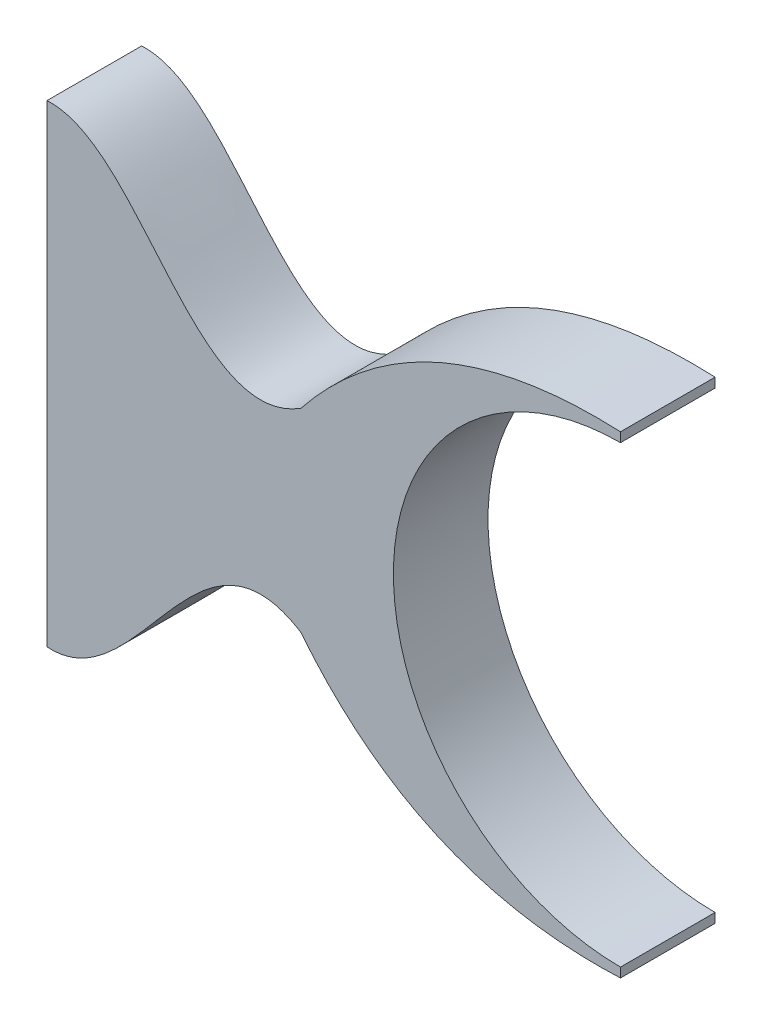
from build123d import *

# Parameters (mm, degrees)
BOSS_EXTRUDE1_DEPTH = 1


with BuildPart() as part:
    # Sketch1 → Boss-Extrude1 (new body)
    with BuildSketch(Plane.XY):
        with BuildLine():
            Line((-6.062552239, 2.5), (-6.062552239, -2.5))
            add(Edge.make_bspline(
                [(-3.378314474, -1.025559537), (-4.49216768, -0.325238314), (-5.082460235, -2.568455815), (-6.062552239, -2.5)],
                knots=[0, 0, 0, 0, 1, 1, 1, 1], degree=3))
            add(Edge.make_bspline(
                [(0, -2.5), (-2.128381344, -2.596064875), (-3.378314474, -1.025559537)],
                knots=[0, 0, 0, 1, 1, 1], degree=2))
            Line((0, -2.5), (0, -2.4))
            ThreePointArc((0, -2.4), (-2.4, 0), (0, 2.4))
            Line((0, 2.4), (0, 2.5))
            add(Edge.make_bspline(
                [(0, 2.5), (-2.128381344, 2.596064875), (-3.378314474, 1.025559537)],
                knots=[0, 0, 0, 1, 1, 1], degree=2))
            add(Edge.make_bspline(
                [(-3.378314474, 1.025559537), (-4.49216768, 0.325238314), (-5.082460235, 2.568455815), (-6.062552239, 2.5)],
                knots=[0, 0, 0, 0, 1, 1, 1, 1], degree=3))
        make_face()
    extrude(amount=BOSS_EXTRUDE1_DEPTH)


solid = part.part
